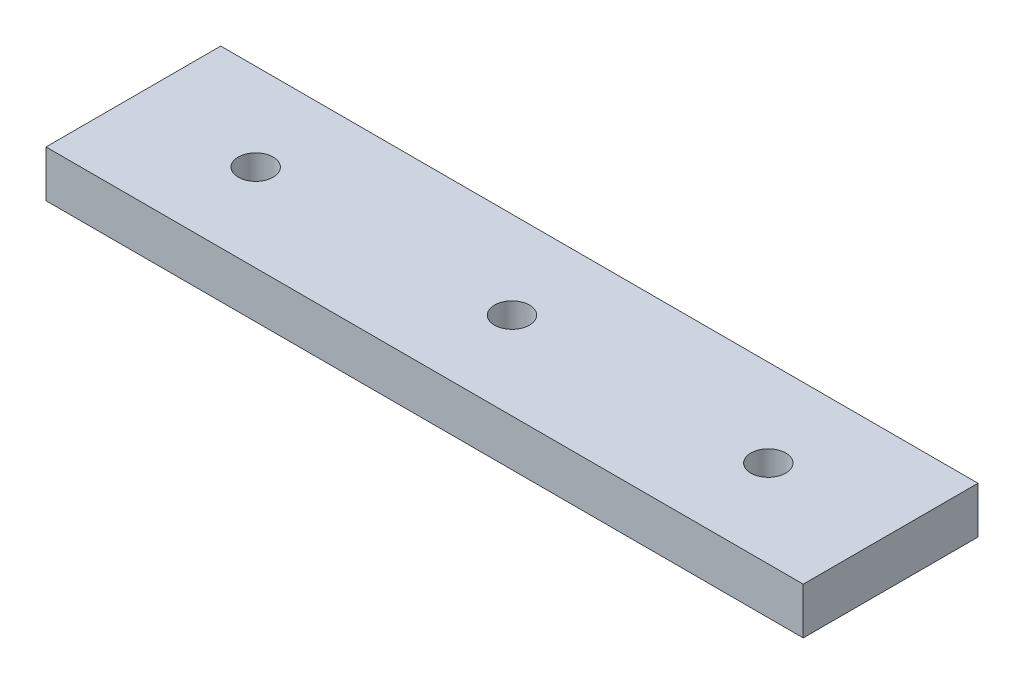
from build123d import *

# Parameters (mm, degrees)
CROQUIS1_W              = 65
CROQUIS1_H              = 15
SALIENTE_EXTRUIR1_DEPTH = 4
CROQUIS2_R              = 1.5
CORTAR_EXTRUIR1_DEPTH   = 5


with BuildPart() as part:
    # Croquis1 → Saliente-Extruir1 (new body)
    with BuildSketch(Plane(origin=(0, 0, 0), x_dir=(1, 0, 0), z_dir=(0, 1, 0))):
        Rectangle(CROQUIS1_W, CROQUIS1_H)
    extrude(amount=SALIENTE_EXTRUIR1_DEPTH)

    # Croquis2 → Cortar-Extruir1 (cut, through all)
    with BuildSketch(Plane(origin=(0, 4, 0), x_dir=(1, 0, 0), z_dir=(0, 1, 0))):
        with Locations((-22, 0)):
            Circle(CROQUIS2_R)
        Circle(CROQUIS2_R)
        with Locations((22, 0)):
            Circle(CROQUIS2_R)
    extrude(amount=-CORTAR_EXTRUIR1_DEPTH, mode=Mode.SUBTRACT)


solid = part.part
